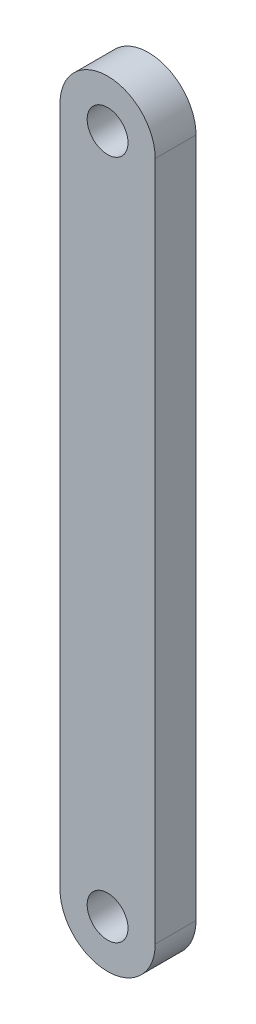
from build123d import *

# Parameters (mm, degrees)
SKETCH1_R           = 1.5
BOSS_EXTRUDE1_DEPTH = 1.5


with BuildPart() as part:
    # Sketch1 → Boss-Extrude1 (new body, symmetric)
    with BuildSketch(Plane.XY):
        with BuildLine():
            Line((3.5, 25), (3.5, -25))
            ThreePointArc((3.5, -25), (0, -28.5), (-3.5, -25))
            Line((-3.5, -25), (-3.5, 25))
            ThreePointArc((-3.5, 25), (0, 28.5), (3.5, 25))
        make_face()
        with Locations((0, -25)):
            Circle(SKETCH1_R, mode=Mode.SUBTRACT)
        with Locations((0, 25)):
            Circle(SKETCH1_R, mode=Mode.SUBTRACT)
    extrude(amount=BOSS_EXTRUDE1_DEPTH, both=True)


solid = part.part
